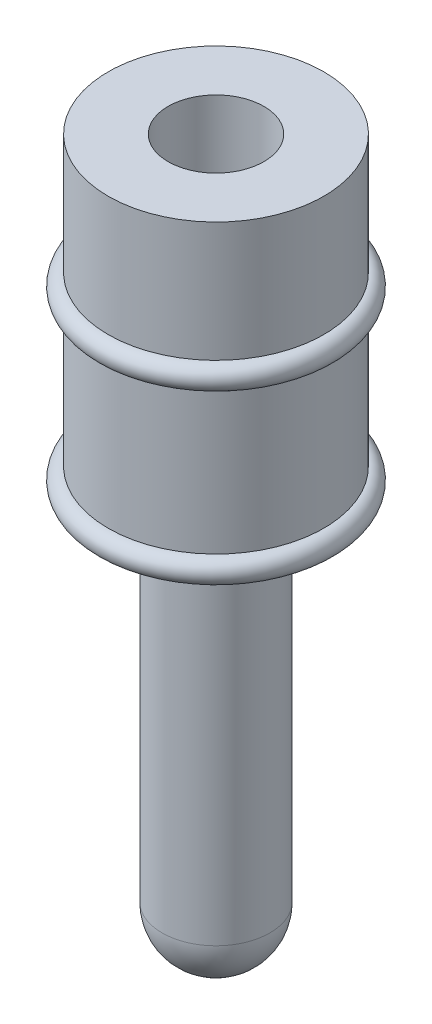
from build123d import *


with BuildPart() as part:
    # Skizze1 → Rotation1 (revolve)
    with BuildSketch(Plane.XY):
        with BuildLine():
            Line((-2.25, 15), (-2.25, 8.5))
            Line((-2.25, 8.5), (-1.125, 8))
            Line((-1.125, 8), (-1.125, 1.125))
            ThreePointArc((-1.125, 1.125), (-0.795495129, 0.329504871), (0, 0))
            Line((0, 0), (0, 15))
            Line((0, 15), (-2.25, 15))
        make_face()
    revolve(axis=Axis((0, 0, 0), (0, 1, 0)))

    # Skizze2 → Schnitt-Rotation1 (revolve, cut)
    with BuildSketch(Plane.XY):
        Polygon((0, 15), (0, 11), (-1.375, 11), (-1.375, 13), (-1, 13), (-1, 15), align=None)
    revolve(axis=Axis((0, 15, 0), (0, -1, 0)), mode=Mode.SUBTRACT)

    # Skizze3 → Rotation2 (revolve)
    with BuildSketch(Plane.XY):
        with BuildLine():
            Line((-2.25, 12.5), (-2.25, 12))
            ThreePointArc((-2.25, 12), (-2.5, 12.25), (-2.25, 12.5))
        make_face()
        with BuildLine():
            Line((-2.25, 9), (-2.25, 8.5))
            ThreePointArc((-2.25, 8.5), (-2.5, 8.75), (-2.25, 9))
        make_face()
    revolve(axis=Axis((0, 0, 0), (0, 1, 0)))


solid = part.part
